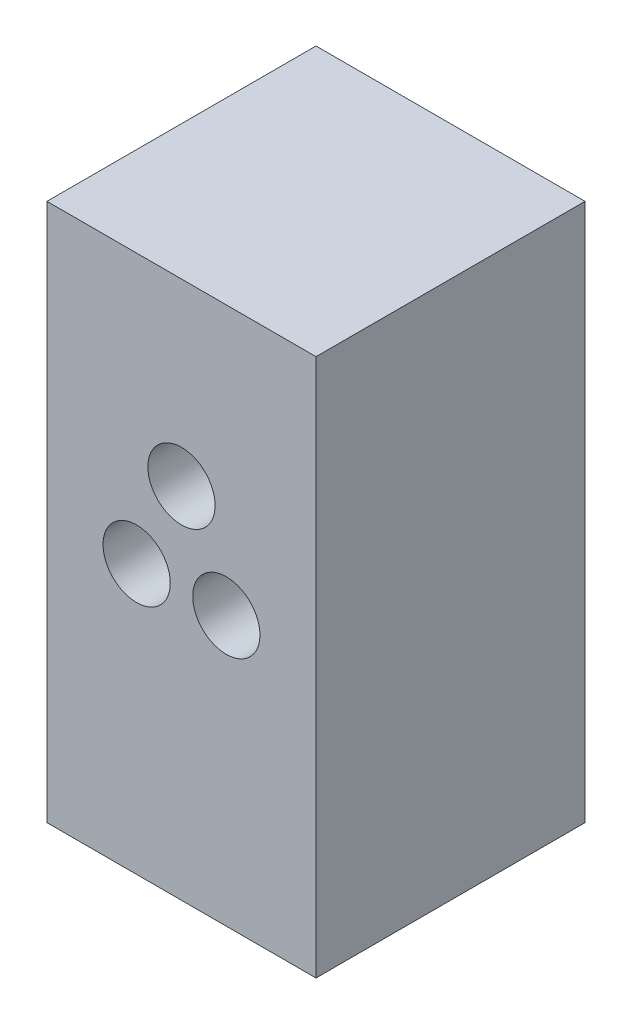
from build123d import *

# Parameters (mm, degrees)
SKETCH1_W           = 6.35
SKETCH1_H           = 12.7
SKETCH1_R           = 0.79375
BOSS_EXTRUDE1_DEPTH = 6.35
CUT_EXTRUDE1_START  = 6.35
SKETCH1_3_R         = 0.79375
CUT_EXTRUDE1_DEPTH  = 1.27


with BuildPart() as part:
    # Sketch1 → Boss-Extrude1 (new body)
    with BuildSketch(Plane.XY):
        Rectangle(SKETCH1_W, SKETCH1_H)
        with Locations((1.058333333, 0)):
            Circle(SKETCH1_R, mode=Mode.SUBTRACT)
        with Locations((-1.058333333, 0)):
            Circle(SKETCH1_R, mode=Mode.SUBTRACT)
        with Locations((0, 2.116666667)):
            Circle(SKETCH1_R, mode=Mode.SUBTRACT)
        with Locations((-1.058333333, 0)):
            Circle(SKETCH1_R)
        with Locations((0, 2.116666667)):
            Circle(SKETCH1_R)
        with Locations((1.058333333, 0)):
            Circle(SKETCH1_R)
    extrude(amount=BOSS_EXTRUDE1_DEPTH)

    # Sketch1_3 → Cut-Extrude1 (cut)
    with BuildSketch(Plane.XY.offset(CUT_EXTRUDE1_START)):
        with Locations((-1.058333333, 0)):
            Circle(SKETCH1_3_R)
        with Locations((0, 2.116666667)):
            Circle(SKETCH1_3_R)
        with Locations((1.058333333, 0)):
            Circle(SKETCH1_3_R)
    extrude(amount=-CUT_EXTRUDE1_DEPTH, mode=Mode.SUBTRACT)


solid = part.part
